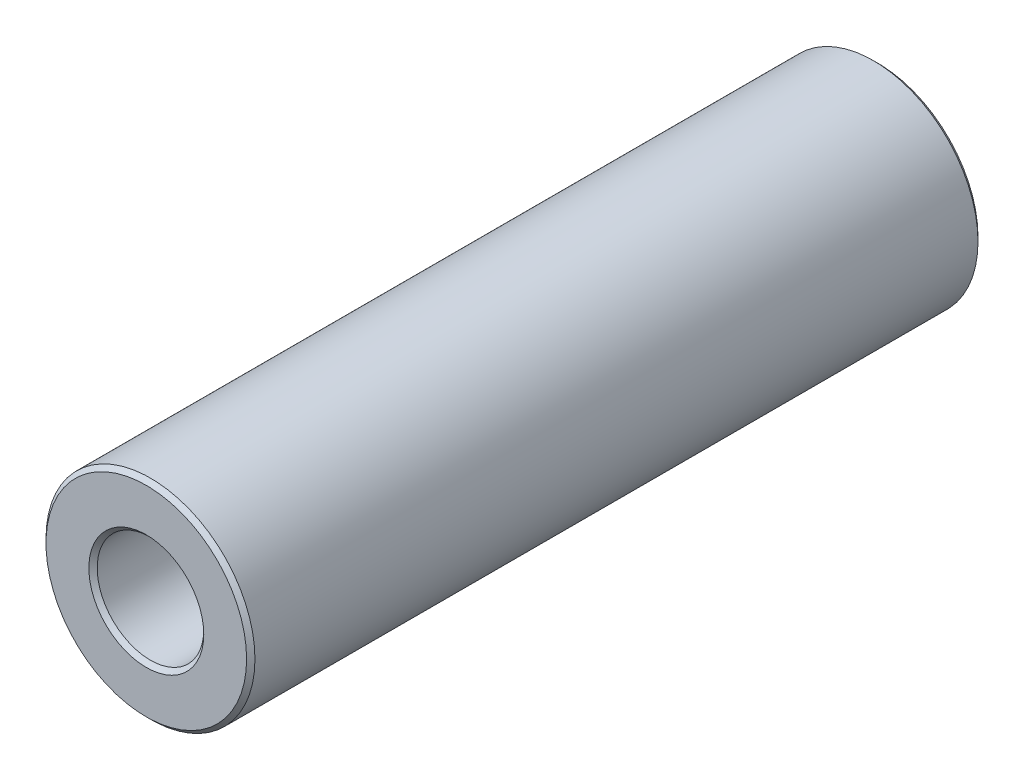
from build123d import *

# Parameters (mm, degrees)
SKETCH1_R           = 5
SKETCH1_R_2         = 2.55
BOSS_EXTRUDE1_DEPTH = 35
CHAMFER1_SIZE       = 0.2


with BuildPart() as part:
    # Sketch1 → Boss-Extrude1 (new body)
    with BuildSketch(Plane.XY):
        Circle(SKETCH1_R)
        Circle(SKETCH1_R_2, mode=Mode.SUBTRACT)
    extrude(amount=BOSS_EXTRUDE1_DEPTH)

    # Chamfer1
    chamfer1_edges = [part.edges().sort_by_distance(p)[0] for p in [
        (-5, 0, 0),
        (-5, 0, 35),
        (-2.55, 0, 0),
        (-2.55, 0, 35),
    ]]
    chamfer(chamfer1_edges, length=CHAMFER1_SIZE)


solid = part.part
